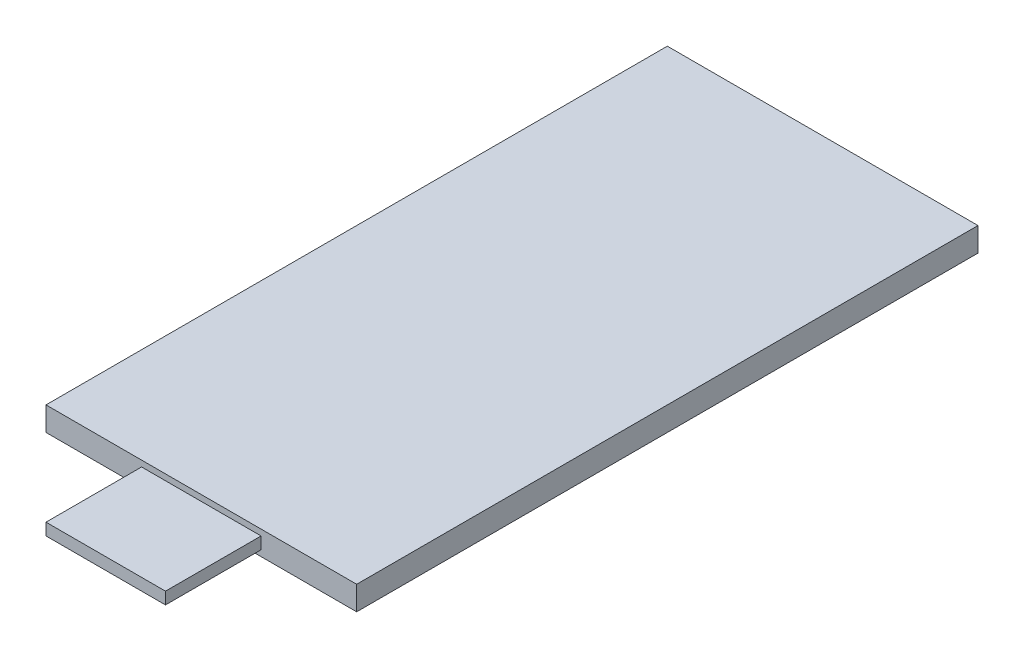
from build123d import *

# Parameters (mm, degrees)
SKETCH1_W           = 26
SKETCH1_H           = 60
BOSS_EXTRUDE1_DEPTH = 2
SKETCH9_W           = 8
SKETCH9_H           = 8
CUT_EXTRUDE1_DEPTH  = 2
SKETCH10_W          = 10
SKETCH10_H          = 8
CUT_EXTRUDE2_DEPTH  = 0.5
SKETCH11_W          = 10
SKETCH11_H          = 8
CUT_EXTRUDE3_DEPTH  = 0.5


with BuildPart() as part:
    # Sketch1 → Boss-Extrude1 (new body)
    with BuildSketch(Plane(origin=(0, 0, 0), x_dir=(1, 0, 0), z_dir=(0, 1, 0))):
        Rectangle(SKETCH1_W, SKETCH1_H)
    extrude(amount=BOSS_EXTRUDE1_DEPTH)

    # Sketch9 → Cut-Extrude1 (cut)
    with BuildSketch(Plane(origin=(0, 2, 0), x_dir=(1, 0, 0), z_dir=(0, 1, 0))):
        with Locations((-9, -26)):
            Rectangle(SKETCH9_W, SKETCH9_H)
        with Locations((9, -26)):
            Rectangle(SKETCH9_W, SKETCH9_H)
    extrude(amount=-CUT_EXTRUDE1_DEPTH, mode=Mode.SUBTRACT)

    # Sketch10 → Cut-Extrude2 (cut)
    with BuildSketch(Plane(origin=(0, 2, 0), x_dir=(1, 0, 0), z_dir=(0, 1, 0))):
        with Locations((0, -26)):
            Rectangle(SKETCH10_W, SKETCH10_H)
    extrude(amount=-CUT_EXTRUDE2_DEPTH, mode=Mode.SUBTRACT)

    # Sketch11 → Cut-Extrude3 (cut)
    with BuildSketch(Plane.XZ):
        with Locations((0, 26)):
            Rectangle(SKETCH11_W, SKETCH11_H)
    extrude(amount=-CUT_EXTRUDE3_DEPTH, mode=Mode.SUBTRACT)


solid = part.part
